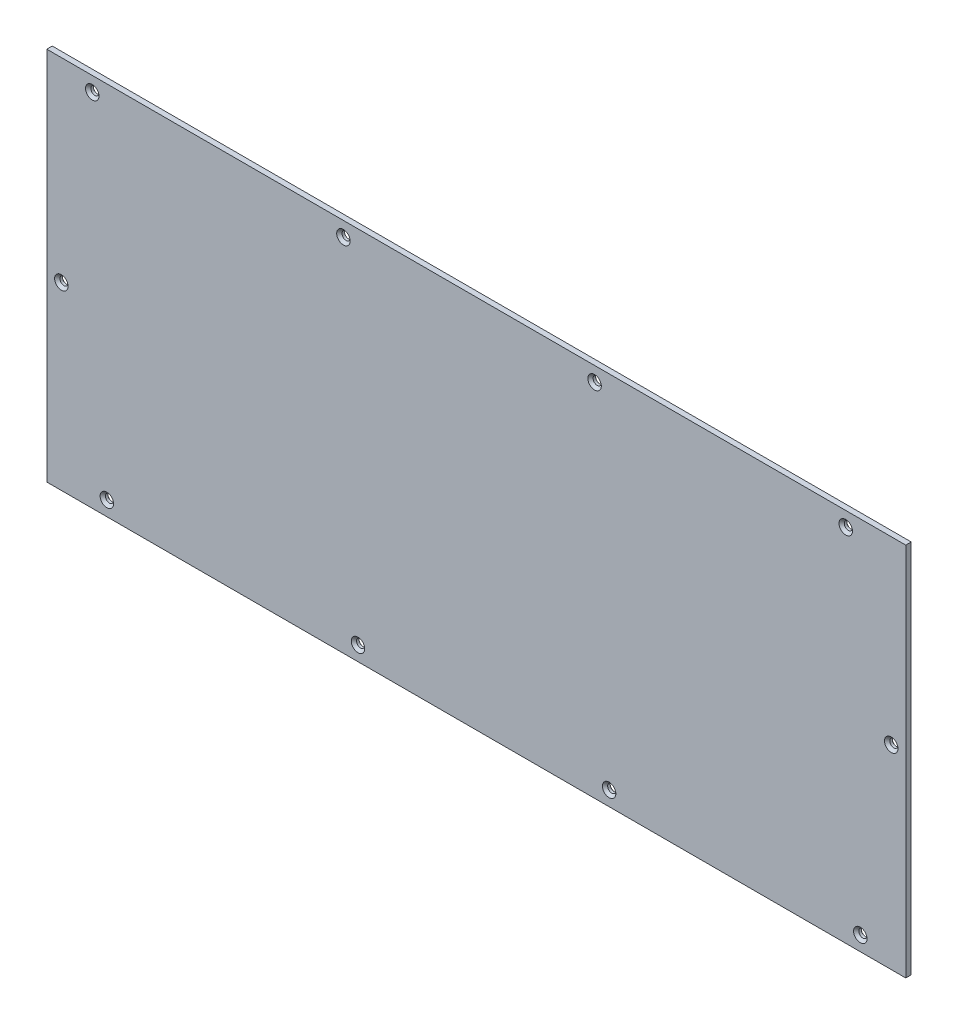
from build123d import *

# Parameters (mm, degrees)
SKETCH_1_W                  = 472
SKETCH_1_H                  = 206
EXTRUDE_1_DEPTH             = 3
HOLE_WIZARD_M41_AT_2_COUNT  = 2
HOLE_WIZARD_M41_AT_2_PITCH  = 138
HOLE_WIZARD_M41_AT_3_COUNT  = 2
HOLE_WIZARD_M41_AT_3_PITCH  = 276
HOLE_WIZARD_M41_AT_4_COUNT  = 2
HOLE_WIZARD_M41_AT_4_PITCH  = 414
HOLE_WIZARD_M41_AT_5_COUNT  = 2
HOLE_WIZARD_M41_AT_5_PITCH  = 462.800172861
HOLE_WIZARD_M41_AT_6_COUNT  = 2
HOLE_WIZARD_M41_AT_6_PITCH  = 341.695771118
HOLE_WIZARD_M41_AT_7_COUNT  = 2
HOLE_WIZARD_M41_AT_7_PITCH  = 239.616360042
HOLE_WIZARD_M41_AT_8_COUNT  = 2
HOLE_WIZARD_M41_AT_8_PITCH  = 190.168346472
HOLE_WIZARD_M41_AT_9_COUNT  = 2
HOLE_WIZARD_M41_AT_9_PITCH  = 100.448992031
HOLE_WIZARD_M41_AT_10_COUNT = 2
HOLE_WIZARD_M41_AT_10_PITCH = 448.332465922


with BuildPart() as part:
    # Эскиз1 → Бобышка-Вытянуть1 (new body)
    with BuildSketch(Plane.XY):
        with Locations((236, 103)):
            Rectangle(SKETCH_1_W, SKETCH_1_H)
    extrude(amount=EXTRUDE_1_DEPTH)

    # Эскиз2 → Зенковка для винта с потайной головкой M41 (revolve, cut)
    with BuildSketch(Plane(origin=(25, 198, 3), x_dir=(0, -1, 0), z_dir=(1, 0, 0))):
        Polygon((0, 0), (0, 3), (2.4, 3), (2.25, 2.85), (2.25, 1.45), (3.7, 0), align=None)
    hole_wizard_m41 = revolve(axis=Axis((25, 198, 9.35), (0, 0, -1)), mode=Mode.SUBTRACT)

    # Зенковка для винта с потайной головкой M41 at 2: Зенковка для винта с потайной головкой M41 ×2
    with Locations(*[(i * HOLE_WIZARD_M41_AT_2_PITCH, 0, 0) for i in range(1, HOLE_WIZARD_M41_AT_2_COUNT)]):
        add(hole_wizard_m41, mode=Mode.SUBTRACT)

    # Зенковка для винта с потайной головкой M41 at 3: Зенковка для винта с потайной головкой M41 ×2
    with Locations(*[(i * HOLE_WIZARD_M41_AT_3_PITCH, 0, 0) for i in range(1, HOLE_WIZARD_M41_AT_3_COUNT)]):
        add(hole_wizard_m41, mode=Mode.SUBTRACT)

    # Зенковка для винта с потайной головкой M41 at 4: Зенковка для винта с потайной головкой M41 ×2
    with Locations(*[(i * HOLE_WIZARD_M41_AT_4_PITCH, 0, 0) for i in range(1, HOLE_WIZARD_M41_AT_4_COUNT)]):
        add(hole_wizard_m41, mode=Mode.SUBTRACT)

    # Зенковка для винта с потайной головкой M41 at 5: Зенковка для винта с потайной головкой M41 ×2
    with Locations(*[Vector(0.911840627, -0.410544358, 0) * (i * HOLE_WIZARD_M41_AT_5_PITCH) for i in range(1, HOLE_WIZARD_M41_AT_5_COUNT)]):
        add(hole_wizard_m41, mode=Mode.SUBTRACT)

    # Зенковка для винта с потайной головкой M41 at 6: Зенковка для винта с потайной головкой M41 ×2
    with Locations(*[Vector(0.831148712, -0.556050195, 0) * (i * HOLE_WIZARD_M41_AT_6_PITCH) for i in range(1, HOLE_WIZARD_M41_AT_6_COUNT)]):
        add(hole_wizard_m41, mode=Mode.SUBTRACT)

    # Зенковка для винта с потайной головкой M41 at 7: Зенковка для винта с потайной головкой M41 ×2
    with Locations(*[Vector(0.609307311, -0.792934172, 0) * (i * HOLE_WIZARD_M41_AT_7_PITCH) for i in range(1, HOLE_WIZARD_M41_AT_7_COUNT)]):
        add(hole_wizard_m41, mode=Mode.SUBTRACT)

    # Зенковка для винта с потайной головкой M41 at 8: Зенковка для винта с потайной головкой M41 ×2
    with Locations(*[Vector(0.042067989, -0.99911475, 0) * (i * HOLE_WIZARD_M41_AT_8_PITCH) for i in range(1, HOLE_WIZARD_M41_AT_8_COUNT)]):
        add(hole_wizard_m41, mode=Mode.SUBTRACT)

    # Зенковка для винта с потайной головкой M41 at 9: Зенковка для винта с потайной головкой M41 ×2
    with Locations(*[Vector(-0.169240125, -0.985574847, 0) * (i * HOLE_WIZARD_M41_AT_9_PITCH) for i in range(1, HOLE_WIZARD_M41_AT_9_COUNT)]):
        add(hole_wizard_m41, mode=Mode.SUBTRACT)

    # Зенковка для винта с потайной головкой M41 at 10: Зенковка для винта с потайной головкой M41 ×2
    with Locations(*[Vector(0.979184051, -0.20297437, 0) * (i * HOLE_WIZARD_M41_AT_10_PITCH) for i in range(1, HOLE_WIZARD_M41_AT_10_COUNT)]):
        add(hole_wizard_m41, mode=Mode.SUBTRACT)


solid = part.part
